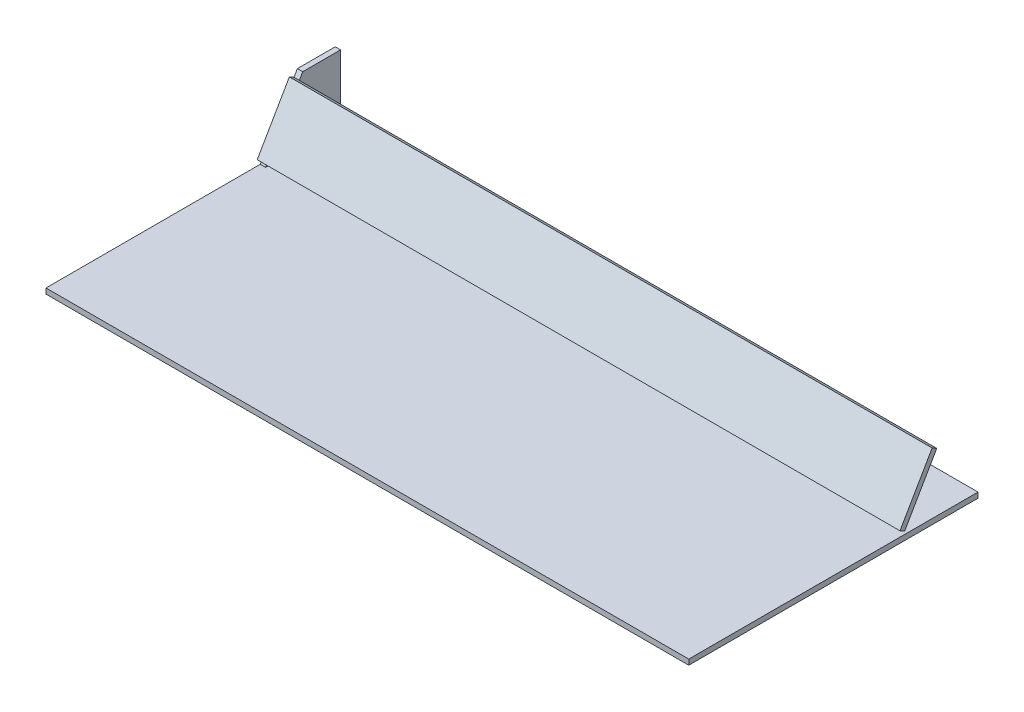
from build123d import *

# Parameters (mm, degrees)
SKETCH1_W           = 600
SKETCH1_H           = 270
BOSS_EXTRUDE1_DEPTH = 5
BOSS_EXTRUDE2_DEPTH = 5
BOSS_EXTRUDE4_DEPTH = 600


with BuildPart() as part:
    # Sketch1 → Boss-Extrude1 (new body)
    with BuildSketch(Plane(origin=(0, 0, 0), x_dir=(1, 0, 0), z_dir=(0, 1, 0))):
        Rectangle(SKETCH1_W, SKETCH1_H)
    extrude(amount=BOSS_EXTRUDE1_DEPTH)


with BuildPart() as body_2:
    # Sketch2 → Boss-Extrude2 (new body)
    with BuildSketch(Plane.ZY.offset(300)):
        Polygon((-99.641016151, 65), (-65, 5), (-135, 5), (-135, 65), align=None)
    extrude(amount=-BOSS_EXTRUDE2_DEPTH)


with BuildPart() as body_3:
    # Sketch3 → Boss-Extrude4 (new body)
    with BuildSketch(Plane.ZY.offset(300)):
        Polygon((-96.5, 59.559600438), (-66.5, 7.598076211), (-62.169872981, 10.098076211), (-92.169872981, 62.059600438), align=None)
    extrude(amount=-BOSS_EXTRUDE4_DEPTH)


solid = Compound([part.part, body_2.part, body_3.part])
